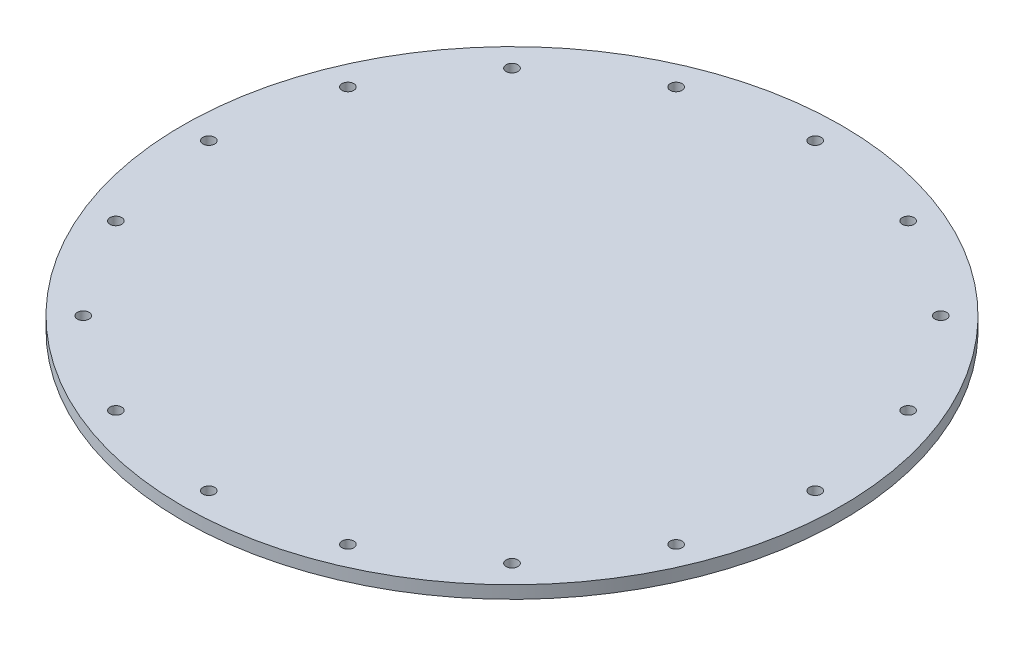
from build123d import *

# Parameters (mm, degrees)
SKETCH1_R           = 79.375
SKETCH1_R_2         = 1.4224
BOSS_EXTRUDE1_DEPTH = 3.048


with BuildPart() as part:
    # Sketch1 → Boss-Extrude1 (new body)
    with BuildSketch(Plane(origin=(0, 0, 0), x_dir=(1, 0, 0), z_dir=(0, 1, 0))):
        Circle(SKETCH1_R)
        with Locations((0, 73.025)):
            Circle(SKETCH1_R_2, mode=Mode.SUBTRACT)
        with Locations((27.945457648, 67.466302862)):
            Circle(SKETCH1_R_2, mode=Mode.SUBTRACT)
        with Locations((51.636472696, 51.636472696)):
            Circle(SKETCH1_R_2, mode=Mode.SUBTRACT)
        with Locations((67.466302862, 27.945457648)):
            Circle(SKETCH1_R_2, mode=Mode.SUBTRACT)
        with Locations((73.025, 0)):
            Circle(SKETCH1_R_2, mode=Mode.SUBTRACT)
        with Locations((67.466302862, -27.945457648)):
            Circle(SKETCH1_R_2, mode=Mode.SUBTRACT)
        with Locations((51.636472696, -51.636472696)):
            Circle(SKETCH1_R_2, mode=Mode.SUBTRACT)
        with Locations((27.945457648, -67.466302862)):
            Circle(SKETCH1_R_2, mode=Mode.SUBTRACT)
        with Locations((0, -73.025)):
            Circle(SKETCH1_R_2, mode=Mode.SUBTRACT)
        with Locations((-27.945457648, -67.466302862)):
            Circle(SKETCH1_R_2, mode=Mode.SUBTRACT)
        with Locations((-51.636472696, -51.636472696)):
            Circle(SKETCH1_R_2, mode=Mode.SUBTRACT)
        with Locations((-67.466302862, -27.945457648)):
            Circle(SKETCH1_R_2, mode=Mode.SUBTRACT)
        with Locations((-73.025, 0)):
            Circle(SKETCH1_R_2, mode=Mode.SUBTRACT)
        with Locations((-67.466302862, 27.945457648)):
            Circle(SKETCH1_R_2, mode=Mode.SUBTRACT)
        with Locations((-51.636472696, 51.636472696)):
            Circle(SKETCH1_R_2, mode=Mode.SUBTRACT)
        with Locations((-27.945457648, 67.466302862)):
            Circle(SKETCH1_R_2, mode=Mode.SUBTRACT)
    extrude(amount=BOSS_EXTRUDE1_DEPTH)


solid = part.part
